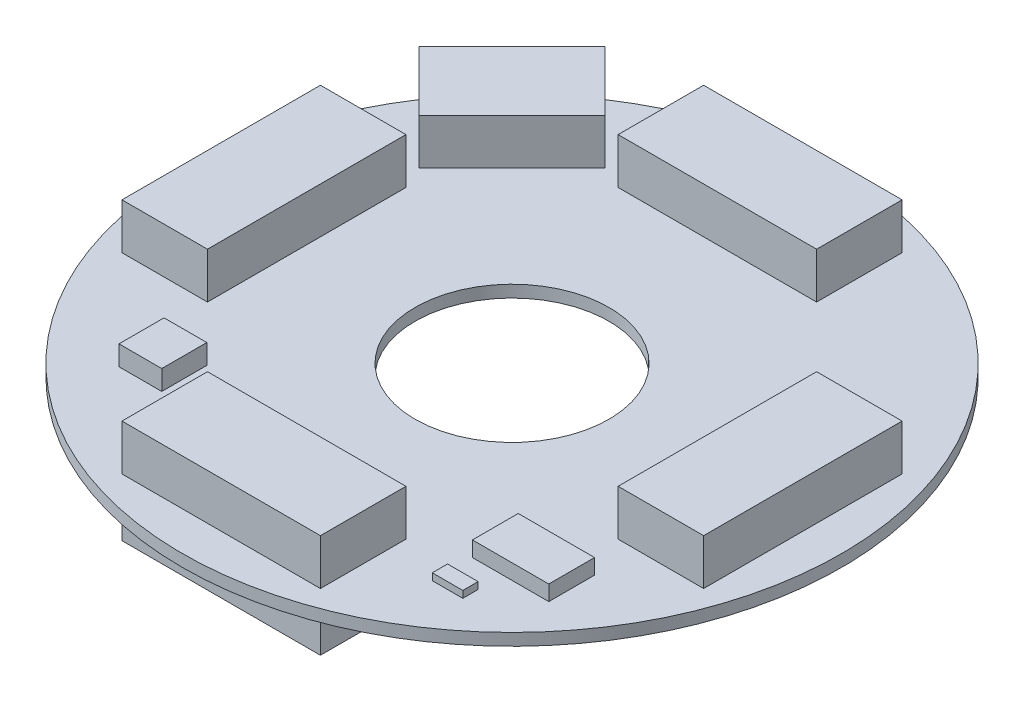
from build123d import *

# Parameters (mm, degrees)
SKETCH1_R                         = 21.59
SKETCH1_R_2                       = 6.35
BOSS_EXTRUDE1_DEPTH               = 0.7874
SKETCH2_W                         = 5.6
SKETCH2_H                         = 13
SKETCH2_W_2                       = 13
SKETCH2_H_2                       = 5.6
FACE_BOARD_CONNECTORS_DEPTH       = 3
SKETCH3_W                         = 13
SKETCH3_H                         = 5.6
BOTTOM_FACE_BOARD_CONNECTOR_DEPTH = 3
PROGRAMMING_CONNECTOR_DEPTH       = 3
SKETCH5_W                         = 2.8
SKETCH5_H                         = 2.95
I2C_TRANSLATOR_DEPTH              = 1.3
SKETCH6_W                         = 5
SKETCH6_H                         = 3
ACCELEROMETER_DEPTH               = 1
SKETCH7_W                         = 2
SKETCH7_H                         = 1
BOSS_EXTRUDE7_DEPTH               = 0.45
BOSS_EXTRUDE8_DEPTH               = 1.2
SKETCH9_W                         = 2.69
SKETCH9_H                         = 6.5
BOSS_EXTRUDE9_DEPTH               = 2.69


with BuildPart() as part:
    # Sketch1 → Boss-Extrude1 (new body)
    with BuildSketch(Plane(origin=(0, 0, 0), x_dir=(1, 0, 0), z_dir=(0, 1, 0))):
        Circle(SKETCH1_R)
        Circle(SKETCH1_R_2, mode=Mode.SUBTRACT)
    extrude(amount=BOSS_EXTRUDE1_DEPTH)

    # Sketch2 → Face Board Connectors (add)
    with BuildSketch(Plane(origin=(0, 0.7874, 0), x_dir=(1, 0, 0), z_dir=(0, 1, 0))):
        with Locations((-16.25, 0)):
            Rectangle(SKETCH2_W, SKETCH2_H)
        with Locations((0, 16.25)):
            Rectangle(SKETCH2_W_2, SKETCH2_H_2)
        with Locations((0, -16.25)):
            Rectangle(SKETCH2_W_2, SKETCH2_H_2)
        with Locations((16.25, 0)):
            Rectangle(SKETCH2_W, SKETCH2_H)
    extrude(amount=FACE_BOARD_CONNECTORS_DEPTH)

    # Sketch3 → Bottom Face Board Connector (add)
    with BuildSketch(Plane.XZ):
        with Locations((0, 16.25)):
            Rectangle(SKETCH3_W, SKETCH3_H)
    extrude(amount=BOTTOM_FACE_BOARD_CONNECTOR_DEPTH)

    # Sketch4 → Programming Connector (add)
    with BuildSketch(Plane(origin=(0, 0.7874, 0), x_dir=(1, 0, 0), z_dir=(0, 1, 0))):
        Polygon((-18.00114237, 11.920024051), (-14.112055073, 8.030936755), (-8.030936755, 14.112055073), (-11.920024051, 18.00114237), align=None)
    extrude(amount=PROGRAMMING_CONNECTOR_DEPTH)

    # Sketch5 → I2C Translator (add)
    with BuildSketch(Plane(origin=(0, 0.7874, 0), x_dir=(1, 0, 0), z_dir=(0, 1, 0))):
        with Locations((-11.276551559, -11.592117418)):
            Rectangle(SKETCH5_W, SKETCH5_H)
    extrude(amount=I2C_TRANSLATOR_DEPTH)

    # Sketch6 → Accelerometer (add)
    with BuildSketch(Plane(origin=(0, 0.7874, 0), x_dir=(1, 0, 0), z_dir=(0, 1, 0))):
        with Locations((12.21999094, -10.814372721)):
            Rectangle(SKETCH6_W, SKETCH6_H)
    extrude(amount=ACCELEROMETER_DEPTH)

    # Sketch7 → Boss-Extrude7 (add)
    with BuildSketch(Plane(origin=(0, 0.7874, 0), x_dir=(1, 0, 0), z_dir=(0, 1, 0))):
        with Locations((10.71999094, -14.443290742)):
            Rectangle(SKETCH7_W, SKETCH7_H)
    extrude(amount=BOSS_EXTRUDE7_DEPTH)

    # Sketch8 → Boss-Extrude8 (add)
    with BuildSketch(Plane.XZ):
        Polygon((-9.844993145, -16.845350279), (-2.844636011, -9.844993145), (-9.844993145, -2.844636011), (-16.845350279, -9.844993145), align=None)
    extrude(amount=BOSS_EXTRUDE8_DEPTH)

    # Sketch9 → Boss-Extrude9 (add)
    with BuildSketch(Plane.XZ):
        with Locations((-10.391917908, 8.664203432)):
            Rectangle(SKETCH9_W, SKETCH9_H)
    extrude(amount=BOSS_EXTRUDE9_DEPTH)


solid = part.part
